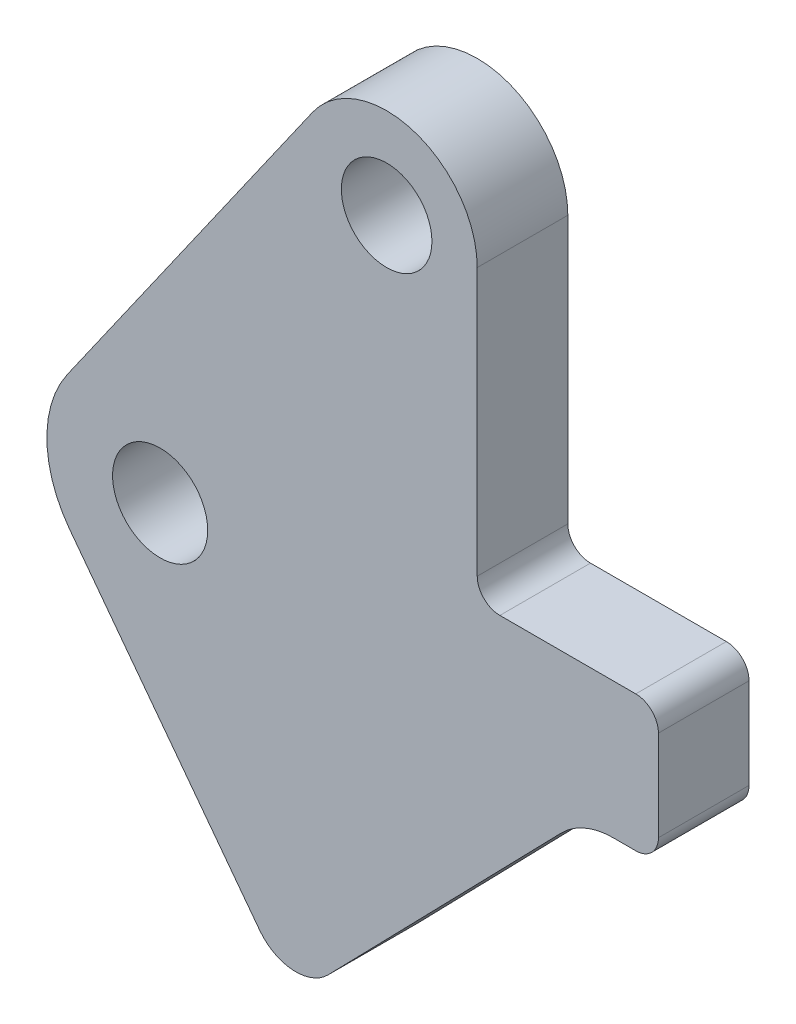
from build123d import *

# Parameters (mm, degrees)
SKETCH_1_R      = 1.05
SKETCH_1_R_2    = 1
EXTRUDE_1_DEPTH = 2


with BuildPart() as part:
    # 草图1 → 凸台-拉伸1 (new body)
    with BuildSketch(Plane.XY):
        with BuildLine():
            Line((10, -1.4), (10.5, -1.4))
            ThreePointArc((10.5, -1.4), (10.853553391, -1.253553391), (11, -0.9))
            Line((11, -0.9), (11, 1.1))
            ThreePointArc((11, 1.1), (10.853553391, 1.453553391), (10.5, 1.6))
            Line((10.5, 1.6), (7.5, 1.6))
            ThreePointArc((7.5, 1.6), (7.146446609, 1.746446609), (7, 2.1))
            Line((7, 2.1), (7, 8))
            ThreePointArc((7, 8), (5.602135251, 9.907205584), (3.36256686, 9.148395712))
            Line((3.36256686, 9.148395712), (-2.046791425, 1.435494641))
            ThreePointArc((-2.046791425, 1.435494641), (-2.499635612, -0.042682638), (-1.996588775, -1.504537558))
            Line((-1.996588775, -1.504537558), (2.196410118, -7.068835026))
            ThreePointArc((2.196410118, -7.068835026), (2.931927352, -7.465026056), (3.711498172, -7.164655833))
            Line((3.711498172, -7.164655833), (8.85367593, -1.883782671))
            ThreePointArc((8.85367593, -1.883782671), (9.377885753, -1.525898964), (10, -1.4))
        make_face()
        Circle(SKETCH_1_R, mode=Mode.SUBTRACT)
        with Locations((5, 8)):
            Circle(SKETCH_1_R_2, mode=Mode.SUBTRACT)
    extrude(amount=EXTRUDE_1_DEPTH)


solid = part.part
